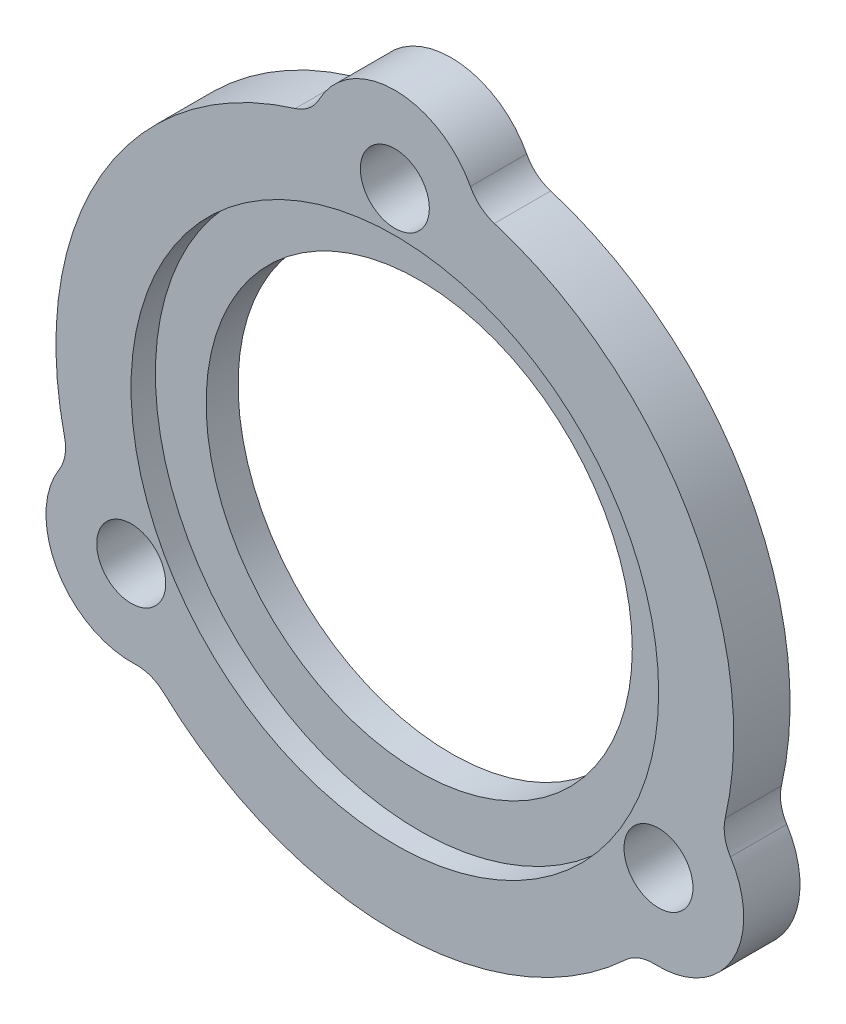
from build123d import *

# Parameters (mm, degrees)
SKETCH1_R           = 2.159
SKETCH1_R_2         = 16.51
BOSS_EXTRUDE1_DEPTH = 1.524
SKETCH2_R           = 2.159
SKETCH2_R_2         = 13.335
BOSS_EXTRUDE2_DEPTH = 2
FILLET1_R           = 2.54


with BuildPart() as part:
    # Sketch1 → Boss-Extrude1 (new body)
    with BuildSketch(Plane.XY):
        with BuildLine():
            ThreePointArc((15.272530034, -14.716368688), (21.117163446, -12.192), (20.381014152, -5.868214645))
            ThreePointArc((20.381014152, -5.868214645), (18.367532789, 10.6045), (5.108484119, 20.584583333))
            ThreePointArc((5.108484119, 20.584583333), (0, 24.384), (-5.108484119, 20.584583333))
            ThreePointArc((-5.108484119, 20.584583333), (-18.367532789, 10.6045), (-20.381014152, -5.868214645))
            ThreePointArc((-20.381014152, -5.868214645), (-21.117163446, -12.192), (-15.272530034, -14.716368688))
            ThreePointArc((-15.272530034, -14.716368688), (0, -21.209), (15.272530034, -14.716368688))
        make_face()
        with Locations((0, 19.05)):
            Circle(SKETCH1_R, mode=Mode.SUBTRACT)
        with Locations((16.497783942, -9.525)):
            Circle(SKETCH1_R, mode=Mode.SUBTRACT)
        with Locations((-16.497783942, -9.525)):
            Circle(SKETCH1_R, mode=Mode.SUBTRACT)
        Circle(SKETCH1_R_2, mode=Mode.SUBTRACT)
    extrude(amount=BOSS_EXTRUDE1_DEPTH)

    # Sketch2 → Boss-Extrude2 (add)
    with BuildSketch(Plane.XY):
        with BuildLine():
            ThreePointArc((-20.381014152, -5.868214645), (-21.117163446, -12.192), (-15.272530034, -14.716368688))
            ThreePointArc((-15.272530034, -14.716368688), (0, -21.209), (15.272530034, -14.716368688))
            ThreePointArc((15.272530034, -14.716368688), (21.117163446, -12.192), (20.381014152, -5.868214645))
            ThreePointArc((20.381014152, -5.868214645), (18.367532789, 10.6045), (5.108484119, 20.584583333))
            ThreePointArc((5.108484119, 20.584583333), (0, 24.384), (-5.108484119, 20.584583333))
            ThreePointArc((-5.108484119, 20.584583333), (-18.367532789, 10.6045), (-20.381014152, -5.868214645))
        make_face()
        with Locations((0, 19.05)):
            Circle(SKETCH2_R, mode=Mode.SUBTRACT)
        with Locations((-16.497783942, -9.525)):
            Circle(SKETCH2_R, mode=Mode.SUBTRACT)
        Circle(SKETCH2_R_2, mode=Mode.SUBTRACT)
        with Locations((16.497783942, -9.525)):
            Circle(SKETCH2_R, mode=Mode.SUBTRACT)
    extrude(amount=-BOSS_EXTRUDE2_DEPTH)

    # Fillet1
    fillet1_edges = [part.edges().sort_by_distance(p)[0] for p in [
        (15.272530034, -14.716368688, -0.238),
        (-15.272530034, -14.716368688, -0.238),
        (-20.381014152, -5.868214645, -0.238),
        (-5.108484119, 20.584583333, -0.238),
        (5.108484119, 20.584583333, -0.238),
        (20.381014152, -5.868214645, -0.238),
    ]]
    fillet(fillet1_edges, radius=FILLET1_R)


solid = part.part
